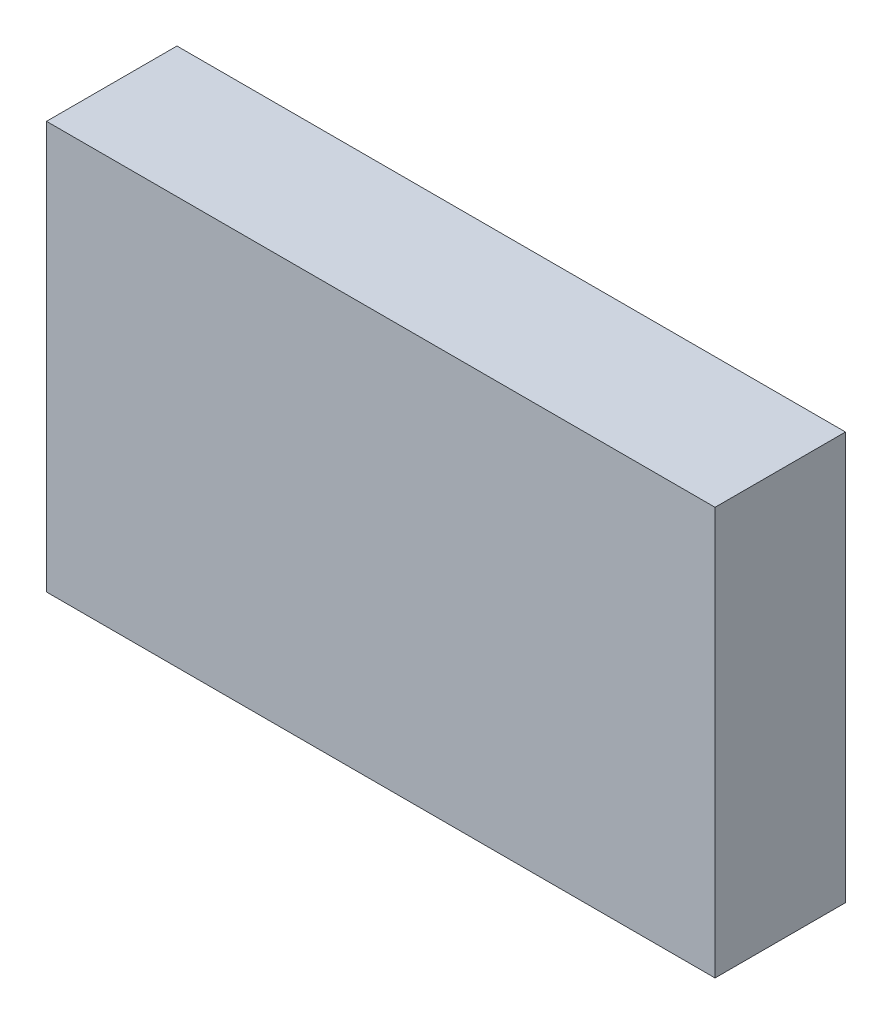
from build123d import *

# Parameters (mm, degrees)
SKETCH_1_W      = 82
SKETCH_1_H      = 50
EXTRUDE_1_DEPTH = 16


with BuildPart() as part:
    # 草图1 → 凸台-拉伸1 (new body)
    with BuildSketch(Plane.XY.offset(16)):
        with Locations((165.906674027, 18.690448813)):
            Rectangle(SKETCH_1_W, SKETCH_1_H)
    extrude(amount=-EXTRUDE_1_DEPTH)


solid = part.part
